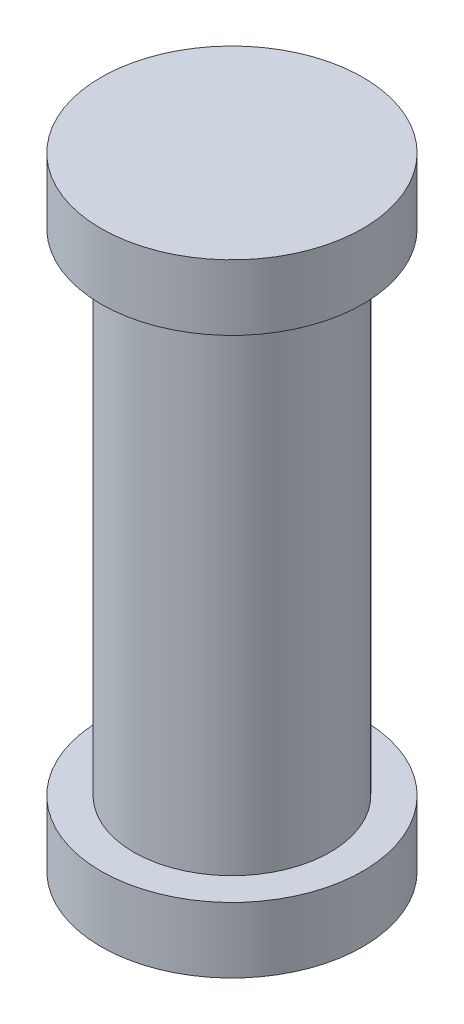
from build123d import *

# Parameters (mm, degrees)
SKETCH1_R           = 1.6
BOSS_EXTRUDE1_DEPTH = 0.8
SKETCH2_R           = 1.2
BOSS_EXTRUDE2_DEPTH = 6
SKETCH3_R           = 1.6
BOSS_EXTRUDE3_DEPTH = 0.8


with BuildPart() as part:
    # Sketch1 → Boss-Extrude1 (new body)
    with BuildSketch(Plane(origin=(0, 0, 0), x_dir=(1, 0, 0), z_dir=(0, 1, 0))):
        Circle(SKETCH1_R)
    extrude(amount=BOSS_EXTRUDE1_DEPTH)

    # Sketch2 → Boss-Extrude2 (add)
    with BuildSketch(Plane(origin=(0, 0.8, 0), x_dir=(1, 0, 0), z_dir=(0, 1, 0))):
        Circle(SKETCH2_R)
    extrude(amount=BOSS_EXTRUDE2_DEPTH)

    # Sketch3 → Boss-Extrude3 (add)
    with BuildSketch(Plane(origin=(0, 6.8, 0), x_dir=(1, 0, 0), z_dir=(0, 1, 0))):
        Circle(SKETCH3_R)
    extrude(amount=BOSS_EXTRUDE3_DEPTH)


solid = part.part
